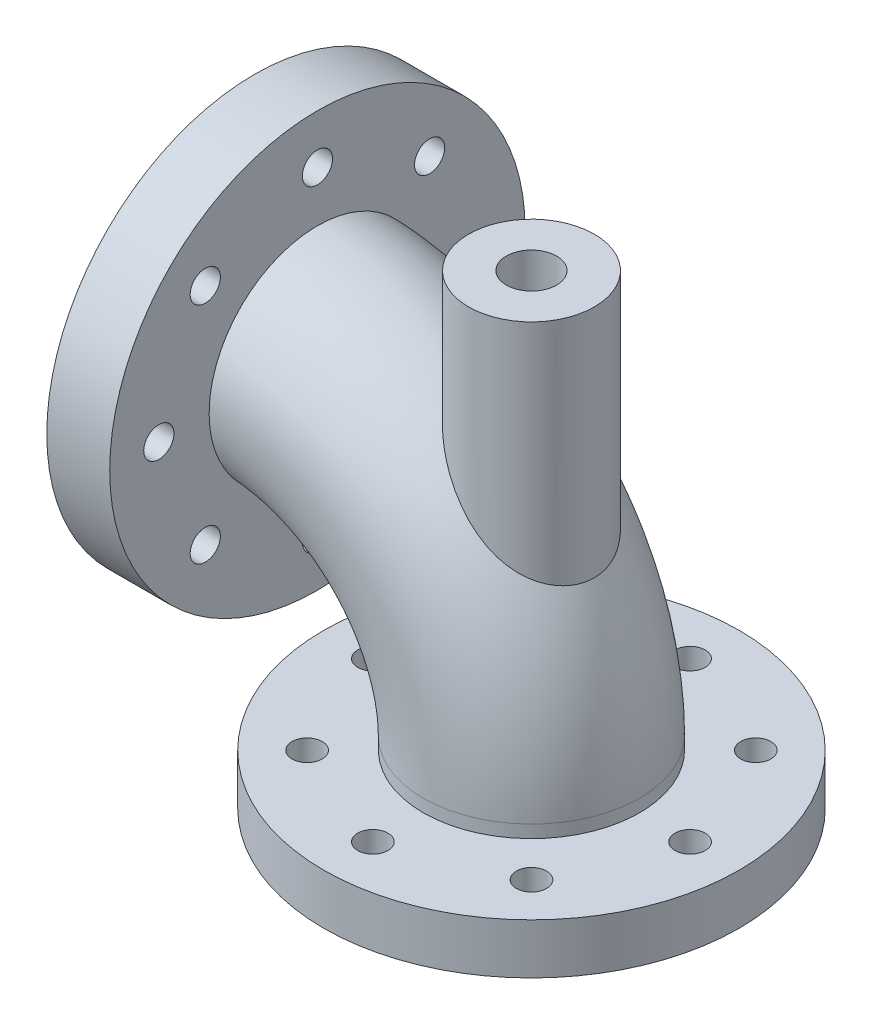
from build123d import *

# Parameters (mm, degrees)
SKETCH6_R           = 43
SKETCH6_R_2         = 27
BOSS_EXTRUDE1_REACH = 187
SKETCH7_R           = 25
CUT_EXTRUDE1_REACH  = 187
SKETCH8_R           = 10
SKETCH9_R           = 82.5
BOSS_EXTRUDE2_DEPTH = 20
SKETCH10_R          = 27
CUT_EXTRUDE2_DEPTH  = 20
SKETCH11_R          = 6
CUT_EXTRUDE3_DEPTH  = 20
SKETCH12_R          = 82.5
BOSS_EXTRUDE3_DEPTH = 25
SKETCH13_R          = 6
CUT_EXTRUDE4_DEPTH  = 25
SKETCH14_R          = 27
CUT_EXTRUDE5_DEPTH  = 25


with BuildPart() as part:
    # Sweep-Thin1: sweep along a path in Sketch5
    with BuildLine(Plane.XY) as sweep_thin1_path:
        Line((0, 0), (0, 25))
        ThreePointArc((0, 25), (-26.360389693, 88.639610307), (-90, 115))
        Line((-90, 115), (-110, 115))
    # Sketch6 → Sweep-Thin1 (sweep)
    with BuildSketch(Plane(origin=(0, 0, 0), x_dir=(1, 0, 0), z_dir=(0, 1, 0))):
        Circle(SKETCH6_R)
        Circle(SKETCH6_R_2, mode=Mode.SUBTRACT)
    sweep(path=sweep_thin1_path.line)

    # Sketch7 → Boss-Extrude1 (add, up to next)
    with BuildSketch(Plane(origin=(0, 185, 0), x_dir=(-1, 0, 0), z_dir=(0, -1, 0)), mode=Mode.PRIVATE) as boss_extrude1_sk1:
        Circle(SKETCH7_R)
    boss_extrude1_tool1 = extrude(boss_extrude1_sk1.sketch, amount=BOSS_EXTRUDE1_REACH, mode=Mode.PRIVATE) - part.part
    add(boss_extrude1_tool1.solids().sort_by_distance((0, 185, 0))[0])

    # Sketch8 → Cut-Extrude1 (cut, up to next)
    with BuildSketch(Plane(origin=(0, 185, 0), x_dir=(1, 0, 0), z_dir=(0, 1, 0)), mode=Mode.PRIVATE) as cut_extrude1_sk1:
        Circle(SKETCH8_R)
    cut_extrude1_tool1 = extrude(cut_extrude1_sk1.sketch, amount=-CUT_EXTRUDE1_REACH, mode=Mode.PRIVATE) & part.part
    add(cut_extrude1_tool1.solids().sort_by_distance((0, 185, 0))[0], mode=Mode.SUBTRACT)

    # Sketch9 → Boss-Extrude2 (add)
    with BuildSketch(Plane.XZ):
        Circle(SKETCH9_R)
    extrude(amount=-BOSS_EXTRUDE2_DEPTH)

    # Sketch10 → Cut-Extrude2 (cut)
    with BuildSketch(Plane.XZ):
        Circle(SKETCH10_R)
    extrude(amount=-CUT_EXTRUDE2_DEPTH, mode=Mode.SUBTRACT)

    # Sketch11 → Cut-Extrude3 (cut)
    with BuildSketch(Plane.XZ):
        with Locations((-63, 0)):
            Circle(SKETCH11_R)
        with Locations((-44.547727215, 44.547727215)):
            Circle(SKETCH11_R)
        with Locations((0, 63)):
            Circle(SKETCH11_R)
        with Locations((44.547727215, 44.547727215)):
            Circle(SKETCH11_R)
        with Locations((63, 0)):
            Circle(SKETCH11_R)
        with Locations((44.547727215, -44.547727215)):
            Circle(SKETCH11_R)
        with Locations((0, -63)):
            Circle(SKETCH11_R)
        with Locations((-44.547727215, -44.547727215)):
            Circle(SKETCH11_R)
    extrude(amount=-CUT_EXTRUDE3_DEPTH, mode=Mode.SUBTRACT)

    # Sketch12 → Boss-Extrude3 (add)
    with BuildSketch(Plane.ZY.offset(110)):
        with Locations((0, 115)):
            Circle(SKETCH12_R)
    extrude(amount=-BOSS_EXTRUDE3_DEPTH)

    # Sketch13 → Cut-Extrude4 (cut)
    with BuildSketch(Plane.ZY.offset(110)):
        with Locations((-63, 115)):
            Circle(SKETCH13_R)
        with Locations((-44.547727215, 159.547727215)):
            Circle(SKETCH13_R)
        with Locations((0, 178)):
            Circle(SKETCH13_R)
        with Locations((44.547727215, 159.547727215)):
            Circle(SKETCH13_R)
        with Locations((63, 115)):
            Circle(SKETCH13_R)
        with Locations((44.547727215, 70.452272785)):
            Circle(SKETCH13_R)
        with Locations((0, 52)):
            Circle(SKETCH13_R)
        with Locations((-44.547727215, 70.452272785)):
            Circle(SKETCH13_R)
    extrude(amount=-CUT_EXTRUDE4_DEPTH, mode=Mode.SUBTRACT)

    # Sketch14 → Cut-Extrude5 (cut)
    with BuildSketch(Plane.ZY.offset(110)):
        with Locations((0, 115)):
            Circle(SKETCH14_R)
    extrude(amount=-CUT_EXTRUDE5_DEPTH, mode=Mode.SUBTRACT)


solid = part.part
